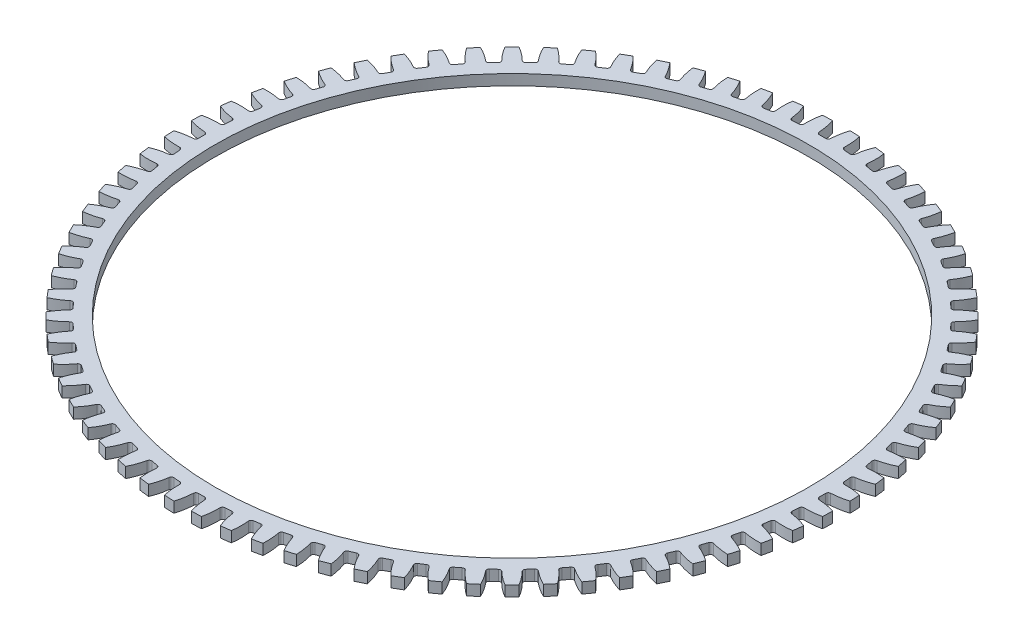
from build123d import *

# Parameters (mm, degrees)
SKETCH1_R                = 393.9
BOSS_EXTRUDE1_DEPTH      = 6.35
CUT_EXTRUDE3_DEPTH       = 558.094913368
FILLET1_R                = 3.03
CIRPATTERN2_COUNT        = 76
FILLET1_OF_CIRPATTERN2_R = 3.03
CUT_EXTRUDE2_DEPTH       = 557.901740691
CUT_EXTRUDE2_DEPTH_BACK  = 557.901740691
SKETCH3_R                = 354.8


with BuildPart() as part:
    # Sketch1 → Boss-Extrude1 (new, symmetric)
    with BuildSketch(Plane(origin=(0, 0, 0), x_dir=(1, 0, 0), z_dir=(0, 1, 0))):
        Circle(SKETCH1_R)
    extrude(amount=BOSS_EXTRUDE1_DEPTH, both=True)

    # Sketch4 → Cut-Extrude3 (cut, symmetric)
    with BuildSketch(Plane(origin=(0, 0, 0), x_dir=(1, 0, 0), z_dir=(0, 1, 0))):
        with BuildLine():
            ThreePointArc((-14.181138298, 403.650969671), (-8.753850637, 387.771343515), (-6.714300921, 371.114266484))
            ThreePointArc((-6.714300921, 371.114266484), (0, 371.175), (6.714300921, 371.114266484))
            ThreePointArc((6.714300921, 371.114266484), (8.753850637, 387.771343515), (14.181138298, 403.650969671))
            ThreePointArc((14.181138298, 403.650969671), (0, 403.9), (-14.181138298, 403.650969671))
        make_face()
    cut_extrude3 = extrude(amount=CUT_EXTRUDE3_DEPTH, both=True, mode=Mode.SUBTRACT)

    # Fillet1
    fillet1_edges = [part.edges().sort_by_distance(p)[0] for p in [
        (6.714300921, 0, -371.114266484),
        (-6.714300921, 0, -371.114266484),
    ]]
    fillet(fillet1_edges, radius=FILLET1_R)

    # CirPattern2: Cut-Extrude3 ×76 about axis
    cirpattern2_axis = Axis((0, 6.35, 0), (0, -1, 0))
    for i in range(1, CIRPATTERN2_COUNT):
        add(cut_extrude3.rotate(cirpattern2_axis, i * 360 / CIRPATTERN2_COUNT), mode=Mode.SUBTRACT)

    # Fillet1 of CirPattern2
    fillet1_of_cirpattern2_edges = [part.edges().sort_by_distance(p)[0] for p in [
        (37.337741401, 0, -369.292260536),
        (23.955005043, 0, -370.401185687),
        (67.706127247, 0, -364.947613992),
        (54.460674032, 0, -367.15788921),
        (97.612011591, 0, -358.110005191),
        (84.594321395, 0, -361.406532056),
        (126.851106919, 0, -348.826141937),
        (114.150103765, 0, -353.186401827),
        (155.223680561, 0, -337.159442428),
        (142.92612518, 0, -342.553650347),
        (182.53591907, 0, -323.189602052),
        (170.725816235, 0, -329.58091009),
        (208.601252162, 0, -307.012048984),
        (197.359276851, 0, -314.356798027),
        (233.241627184, 0, -288.737292315),
        (222.644573486, 0, -296.98531028),
        (256.288725388, 0, -268.490167164),
        (246.408981926, 0, -277.585111724),
        (277.585111724, 0, -246.408981926),
        (268.490167164, 0, -256.288725388),
        (296.98531028, 0, -222.644573486),
        (288.737292315, 0, -233.241627184),
        (314.356798027, 0, -197.359276851),
        (307.012048984, 0, -208.601252162),
        (329.58091009, 0, -170.725816235),
        (323.189602052, 0, -182.53591907),
        (342.553650347, 0, -142.92612518),
        (337.159442428, 0, -155.223680561),
        (353.186401827, 0, -114.150103765),
        (348.826141937, 0, -126.851106919),
        (361.406532056, 0, -84.594321395),
        (358.110005191, 0, -97.612011591),
        (367.15788921, 0, -54.460674032),
        (364.947613992, 0, -67.706127247),
        (370.401185687, 0, -23.955005043),
        (369.292260536, 0, -37.337741401),
        (371.114266484, 0, 6.714300921),
        (371.114266484, 0, -6.714300921),
        (369.292260536, 0, 37.337741401),
        (370.401185687, 0, 23.955005043),
        (364.947613992, 0, 67.706127247),
        (367.15788921, 0, 54.460674032),
        (358.110005191, 0, 97.612011591),
        (361.406532056, 0, 84.594321395),
        (348.826141937, 0, 126.851106919),
        (353.186401827, 0, 114.150103765),
        (337.159442428, 0, 155.223680561),
        (342.553650347, 0, 142.92612518),
        (323.189602052, 0, 182.53591907),
        (329.58091009, 0, 170.725816235),
        (307.012048984, 0, 208.601252162),
        (314.356798027, 0, 197.359276851),
        (288.737292315, 0, 233.241627184),
        (296.98531028, 0, 222.644573486),
        (268.490167164, 0, 256.288725388),
        (277.585111724, 0, 246.408981926),
        (246.408981926, 0, 277.585111724),
        (256.288725388, 0, 268.490167164),
        (222.644573486, 0, 296.98531028),
        (233.241627184, 0, 288.737292315),
        (197.359276851, 0, 314.356798027),
        (208.601252162, 0, 307.012048984),
        (170.725816235, 0, 329.58091009),
        (182.53591907, 0, 323.189602052),
        (142.92612518, 0, 342.553650347),
        (155.223680561, 0, 337.159442428),
        (114.150103765, 0, 353.186401827),
        (126.851106919, 0, 348.826141937),
        (84.594321395, 0, 361.406532056),
        (97.612011591, 0, 358.110005191),
        (54.460674032, 0, 367.15788921),
        (67.706127247, 0, 364.947613992),
        (23.955005043, 0, 370.401185687),
        (37.337741401, 0, 369.292260536),
        (-6.714300921, 0, 371.114266484),
        (6.714300921, 0, 371.114266484),
        (-37.337741401, 0, 369.292260536),
        (-23.955005043, 0, 370.401185687),
        (-67.706127247, 0, 364.947613992),
        (-54.460674032, 0, 367.15788921),
        (-97.612011591, 0, 358.110005191),
        (-84.594321395, 0, 361.406532056),
        (-126.851106919, 0, 348.826141937),
        (-114.150103765, 0, 353.186401827),
        (-155.223680561, 0, 337.159442428),
        (-142.92612518, 0, 342.553650347),
        (-182.53591907, 0, 323.189602052),
        (-170.725816235, 0, 329.58091009),
        (-208.601252162, 0, 307.012048984),
        (-197.359276851, 0, 314.356798027),
        (-233.241627184, 0, 288.737292315),
        (-222.644573486, 0, 296.98531028),
        (-256.288725388, 0, 268.490167164),
        (-246.408981926, 0, 277.585111724),
        (-277.585111724, 0, 246.408981926),
        (-268.490167164, 0, 256.288725388),
        (-296.98531028, 0, 222.644573486),
        (-288.737292315, 0, 233.241627184),
        (-314.356798027, 0, 197.359276851),
        (-307.012048984, 0, 208.601252162),
        (-329.58091009, 0, 170.725816235),
        (-323.189602052, 0, 182.53591907),
        (-342.553650347, 0, 142.92612518),
        (-337.159442428, 0, 155.223680561),
        (-353.186401827, 0, 114.150103765),
        (-348.826141937, 0, 126.851106919),
        (-361.406532056, 0, 84.594321395),
        (-358.110005191, 0, 97.612011591),
        (-367.15788921, 0, 54.460674032),
        (-364.947613992, 0, 67.706127247),
        (-370.401185687, 0, 23.955005043),
        (-369.292260536, 0, 37.337741401),
        (-371.114266484, 0, -6.714300921),
        (-371.114266484, 0, 6.714300921),
        (-369.292260536, 0, -37.337741401),
        (-370.401185687, 0, -23.955005043),
        (-364.947613992, 0, -67.706127247),
        (-367.15788921, 0, -54.460674032),
        (-358.110005191, 0, -97.612011591),
        (-361.406532056, 0, -84.594321395),
        (-348.826141937, 0, -126.851106919),
        (-353.186401827, 0, -114.150103765),
        (-337.159442428, 0, -155.223680561),
        (-342.553650347, 0, -142.92612518),
        (-323.189602052, 0, -182.53591907),
        (-329.58091009, 0, -170.725816235),
        (-307.012048984, 0, -208.601252162),
        (-314.356798027, 0, -197.359276851),
        (-288.737292315, 0, -233.241627184),
        (-296.98531028, 0, -222.644573486),
        (-268.490167164, 0, -256.288725388),
        (-277.585111724, 0, -246.408981926),
        (-246.408981926, 0, -277.585111724),
        (-256.288725388, 0, -268.490167164),
        (-222.644573486, 0, -296.98531028),
        (-233.241627184, 0, -288.737292315),
        (-197.359276851, 0, -314.356798027),
        (-208.601252162, 0, -307.012048984),
        (-170.725816235, 0, -329.58091009),
        (-182.53591907, 0, -323.189602052),
        (-142.92612518, 0, -342.553650347),
        (-155.223680561, 0, -337.159442428),
        (-114.150103765, 0, -353.186401827),
        (-126.851106919, 0, -348.826141937),
        (-84.594321395, 0, -361.406532056),
        (-97.612011591, 0, -358.110005191),
        (-54.460674032, 0, -367.15788921),
        (-67.706127247, 0, -364.947613992),
        (-23.955005043, 0, -370.401185687),
        (-37.337741401, 0, -369.292260536),
    ]]
    fillet(fillet1_of_cirpattern2_edges, radius=FILLET1_OF_CIRPATTERN2_R)

    # Sketch3 → Cut-Extrude2 (cut, two sides: drawn at the far end of the back side and taken through both)
    with BuildSketch(Plane(origin=(0, 0, 0), x_dir=(1, 0, 0), z_dir=(0, 1, 0)).offset(-CUT_EXTRUDE2_DEPTH_BACK)):
        Circle(SKETCH3_R)
    extrude(amount=CUT_EXTRUDE2_DEPTH + CUT_EXTRUDE2_DEPTH_BACK, mode=Mode.SUBTRACT)


solid = part.part
